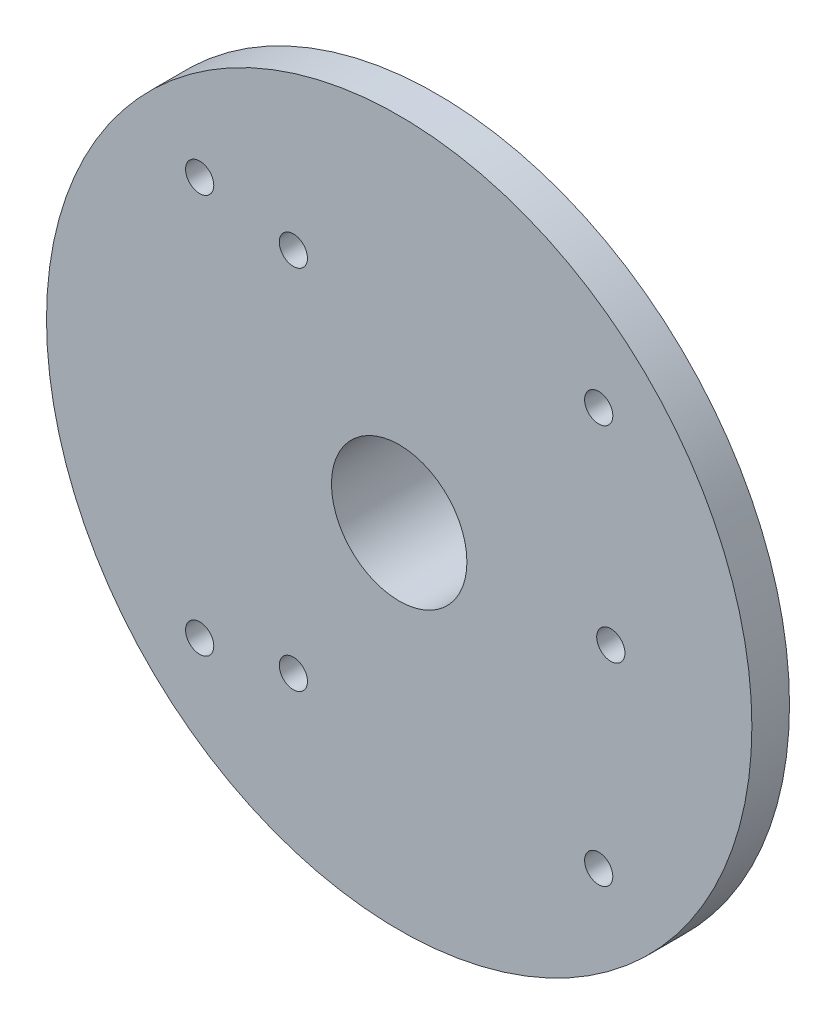
from build123d import *

# Parameters (mm, degrees)
SKETCH1_R           = 37.5
SKETCH1_R_2         = 7.2
SKETCH1_R_3         = 1.5
BOSS_EXTRUDE1_DEPTH = 4
SKETCH2_R           = 11.2
SKETCH2_R_2         = 7.2
BOSS_EXTRUDE2_DEPTH = 8


with BuildPart() as part:
    # Sketch1 → Boss-Extrude1 (new body)
    with BuildSketch(Plane.XY):
        Circle(SKETCH1_R)
        Circle(SKETCH1_R_2, mode=Mode.SUBTRACT)
        with Locations((22.5, 0)):
            Circle(SKETCH1_R_3, mode=Mode.SUBTRACT)
        with Locations((-11.25, -19.485571585)):
            Circle(SKETCH1_R_3, mode=Mode.SUBTRACT)
        with Locations((-11.25, 19.485571585)):
            Circle(SKETCH1_R_3, mode=Mode.SUBTRACT)
        with Locations((21.213203436, 21.213203436)):
            Circle(SKETCH1_R_3, mode=Mode.SUBTRACT)
        with Locations((21.213203436, -21.213203436)):
            Circle(SKETCH1_R_3, mode=Mode.SUBTRACT)
        with Locations((-21.213203436, -21.213203436)):
            Circle(SKETCH1_R_3, mode=Mode.SUBTRACT)
        with Locations((-21.213203436, 21.213203436)):
            Circle(SKETCH1_R_3, mode=Mode.SUBTRACT)
    extrude(amount=BOSS_EXTRUDE1_DEPTH)

    # Sketch2 → Boss-Extrude2 (add)
    with BuildSketch(Plane(origin=(0, 0, 0), x_dir=(-1, 0, 0), z_dir=(0, 0, -1))):
        Circle(SKETCH2_R)
        Circle(SKETCH2_R_2, mode=Mode.SUBTRACT)
    extrude(amount=BOSS_EXTRUDE2_DEPTH)


solid = part.part
